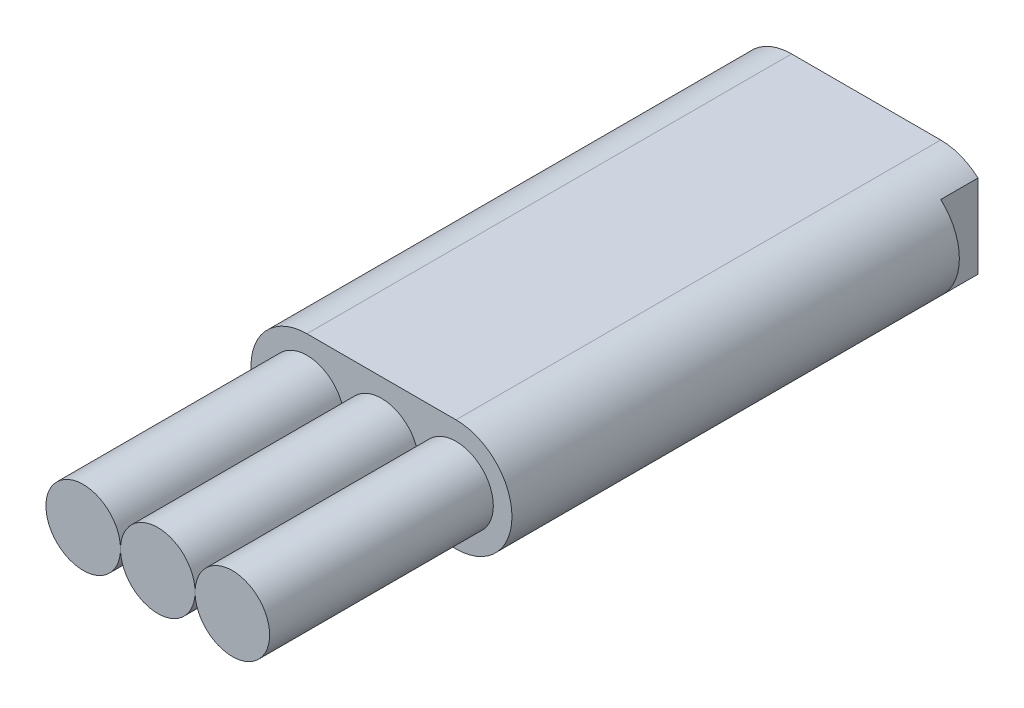
from build123d import *

# Parameters (mm, degrees)
SKETCH_1_R          = 1
EXTRUDE_1_DEPTH     = 6
EXTRUDE_1_2_DEPTH   = 6
EXTRUDE_1_3_DEPTH   = 6
EXTRUDE_5_DEPTH     = 13
SKETCH_3_W          = 1.364124089
SKETCH_3_H          = 6.403769564
SKETCH_3_W_2        = 2.240486341
SKETCH_3_H_2        = 5.419092784
CUT_EXTRUDE_1_DEPTH = 1


with BuildPart() as part:
    # Эскиз1 → Бобышка-Вытянуть1 (new body)
    with BuildSketch(Plane.XY):
        with Locations((-2, 0)):
            Circle(SKETCH_1_R)
    extrude(amount=EXTRUDE_1_DEPTH)


with BuildPart() as body_2:
    # Эскиз1 → Extrude 1 2 (new body)
    with BuildSketch(Plane.XY):
        Circle(SKETCH_1_R)
    extrude(amount=EXTRUDE_1_2_DEPTH)


with BuildPart() as body_3:
    # Эскиз1 → Extrude 1 3 (new body)
    with BuildSketch(Plane.XY):
        with Locations((2, 0)):
            Circle(SKETCH_1_R)
    extrude(amount=EXTRUDE_1_3_DEPTH)


with BuildPart() as body_4:
    # Эскиз2 → Бобышка-Вытянуть5 (new body)
    with BuildSketch(Plane(origin=(0, 0, 0), x_dir=(-1, 0, 0), z_dir=(0, 0, -1))):
        with BuildLine():
            Line((-2, 1.5), (2, 1.5))
            ThreePointArc((2, 1.5), (3.5, 0), (2, -1.5))
            Line((2, -1.5), (-2, -1.5))
            ThreePointArc((-2, -1.5), (-3.5, 0), (-2, 1.5))
        make_face()
    extrude(amount=EXTRUDE_5_DEPTH)

    # Эскиз3 → Вырез-Вытянуть1 (cut)
    with BuildSketch(Plane(origin=(0, 0, -13), x_dir=(-1, 0, 0), z_dir=(0, 0, -1))):
        with Locations((3.682062045, -0.167934068)):
            Rectangle(SKETCH_3_W, SKETCH_3_H)
        with Locations((-4.120243171, 0.324404322)):
            Rectangle(SKETCH_3_W_2, SKETCH_3_H_2)
    extrude(amount=-CUT_EXTRUDE_1_DEPTH, mode=Mode.SUBTRACT)


solid = Compound([part.part, body_2.part, body_3.part, body_4.part])
